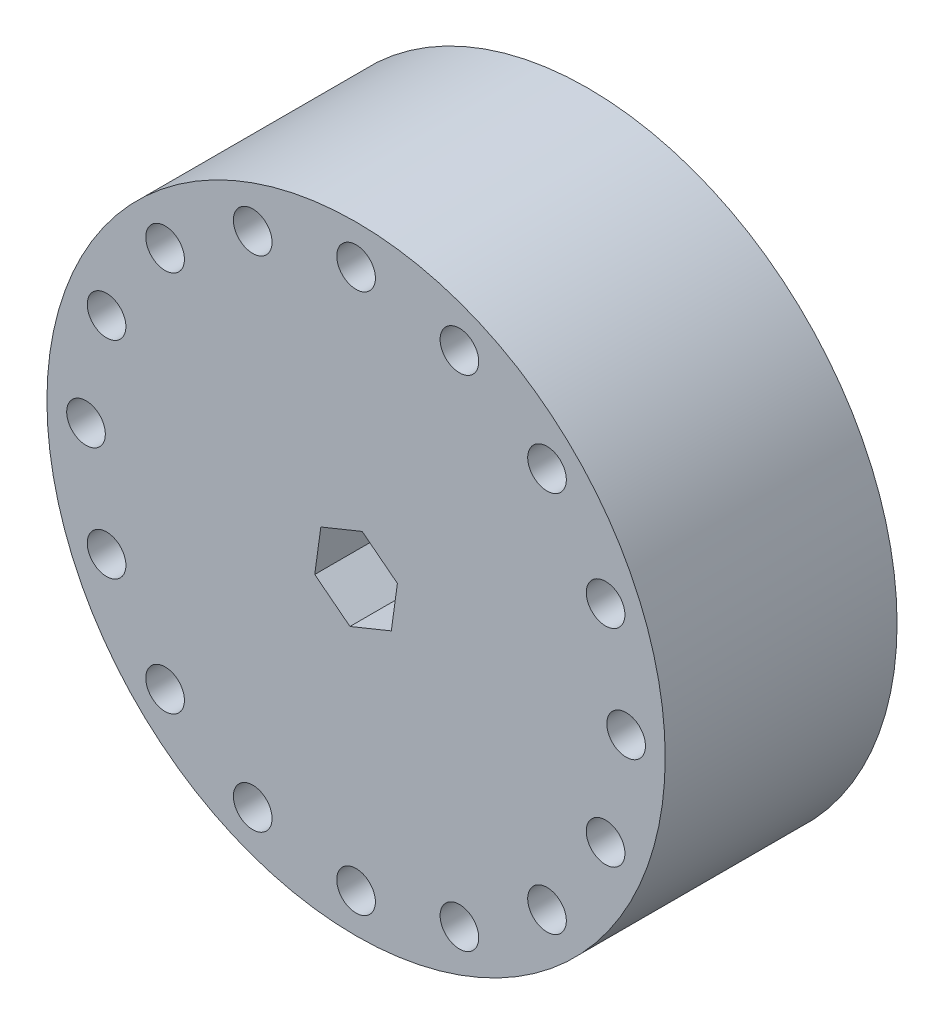
from build123d import *

# Parameters (mm, degrees)
SKETCH1_R           = 50.8
BOSS_EXTRUDE1_DEPTH = 38.1
SKETCH2_R           = 3.175
CUT_EXTRUDE1_DEPTH  = 39.1


with BuildPart() as part:
    # Sketch1 → Boss-Extrude1 (new body)
    with BuildSketch(Plane.XY):
        Circle(SKETCH1_R)
        Polygon((5.789348381, -4.499642059), (6.791478521, 2.76390174), (1.00213014, 7.263543799), (-5.789348381, 4.499642059), (-6.791478521, -2.76390174), (-1.00213014, -7.263543799), align=None, mode=Mode.SUBTRACT)
    extrude(amount=BOSS_EXTRUDE1_DEPTH)

    # Sketch2 → Cut-Extrude1 (cut, through all)
    with BuildSketch(Plane.XY.offset(38.1)):
        with Locations((0, 44.377138181)):
            Circle(SKETCH2_R)
        with Locations((16.982395558, 40.999129677)):
            Circle(SKETCH2_R)
        with Locations((31.379375337, 31.379375337)):
            Circle(SKETCH2_R)
        with Locations((40.999129677, 16.982395558)):
            Circle(SKETCH2_R)
        with Locations((44.377138181, 0)):
            Circle(SKETCH2_R)
        with Locations((40.999129677, -16.982395558)):
            Circle(SKETCH2_R)
        with Locations((31.379375337, -31.379375337)):
            Circle(SKETCH2_R)
        with Locations((16.982395558, -40.999129677)):
            Circle(SKETCH2_R)
        with Locations((0, -44.377138181)):
            Circle(SKETCH2_R)
        with Locations((-16.982395558, -40.999129677)):
            Circle(SKETCH2_R)
        with Locations((-31.379375337, -31.379375337)):
            Circle(SKETCH2_R)
        with Locations((-40.999129677, -16.982395558)):
            Circle(SKETCH2_R)
        with Locations((-44.377138181, 0)):
            Circle(SKETCH2_R)
        with Locations((-40.999129677, 16.982395558)):
            Circle(SKETCH2_R)
        with Locations((-31.379375337, 31.379375337)):
            Circle(SKETCH2_R)
        with Locations((-16.982395558, 40.999129677)):
            Circle(SKETCH2_R)
    extrude(amount=-CUT_EXTRUDE1_DEPTH, mode=Mode.SUBTRACT)


solid = part.part
